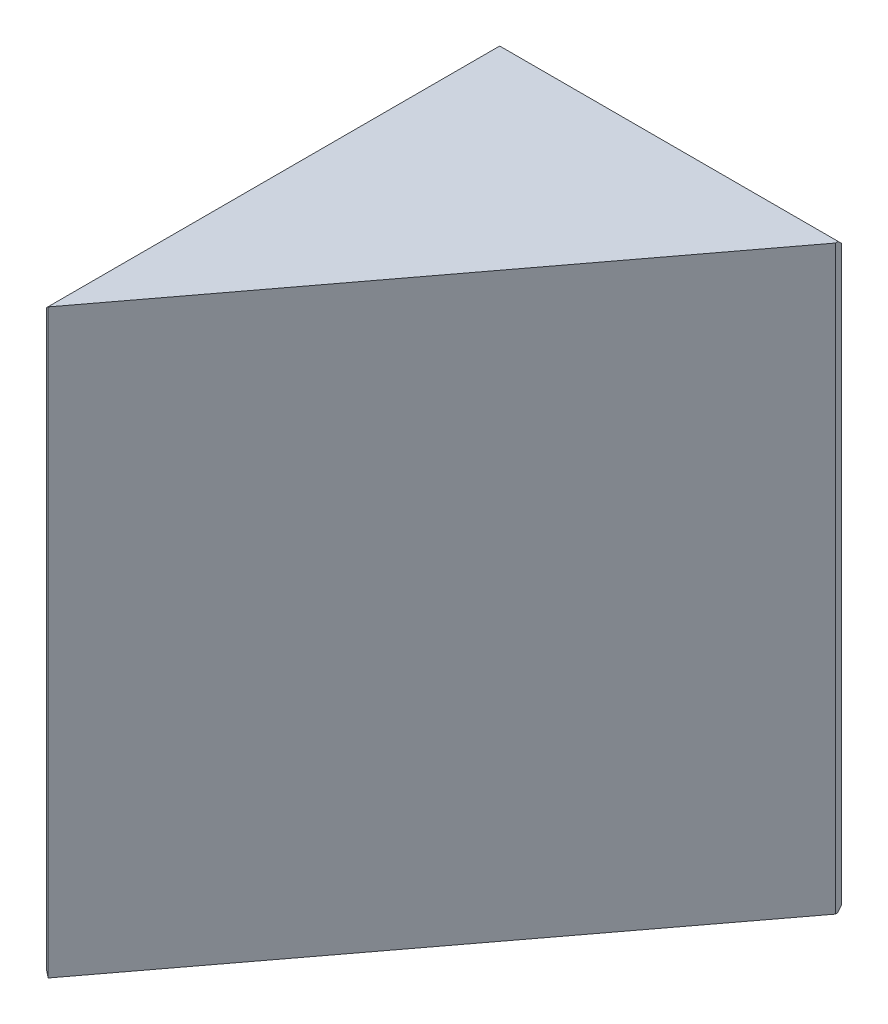
from build123d import *

# Parameters (mm, degrees)
EXTRUDE_1_DEPTH = 20
CHAMFER_1_SIZE  = 0.3
CHAMFER_1_SIZE2 = 0.261758731
CHAMFER_2_SIZE2 = 0.214216777
CHAMFER_2_SIZE  = 0.3
CHAMFER_3_SIZE  = 0.15


with BuildPart() as part:
    # Эскиз1 → Вытянуть1 (new body)
    with BuildSketch(Plane(origin=(0, 0, 0), x_dir=(1, 0, 0), z_dir=(0, 1, 0))):
        Polygon((0, 0), (11.982938249, 15.901896151), (0, 15.901896151), align=None)
    extrude(amount=EXTRUDE_1_DEPTH)

    # Фаска1
    chamfer_1_edges = [part.edges().sort_by_distance(p)[0] for p in [
        (0, 10, 0),
    ]]
    chamfer_1_side = [part.faces().sort_by_distance(p)[0] for p in [
        (0, 10, -7.950948075),
    ]]
    chamfer(chamfer_1_edges, length=CHAMFER_1_SIZE, length2=CHAMFER_1_SIZE2, reference=chamfer_1_side[0])

    # Фаска2
    chamfer_2_edges = [part.edges().sort_by_distance(p)[0] for p in [
        (11.982938249, 10, -15.901896151),
    ]]
    chamfer(chamfer_2_edges, length=CHAMFER_2_SIZE, length2=CHAMFER_2_SIZE2)

    # Фаска3
    chamfer_3_edges = [part.edges().sort_by_distance(p)[0] for p in [
        (5.884360736, 0, -15.901896151),
        (5.884360736, 20, -15.901896151),
        (0, 20, -8.100948075),
        (0, 0, -8.100948075),
        (0, 10, -15.901896151),
    ]]
    chamfer(chamfer_3_edges, length=CHAMFER_3_SIZE)


solid = part.part
